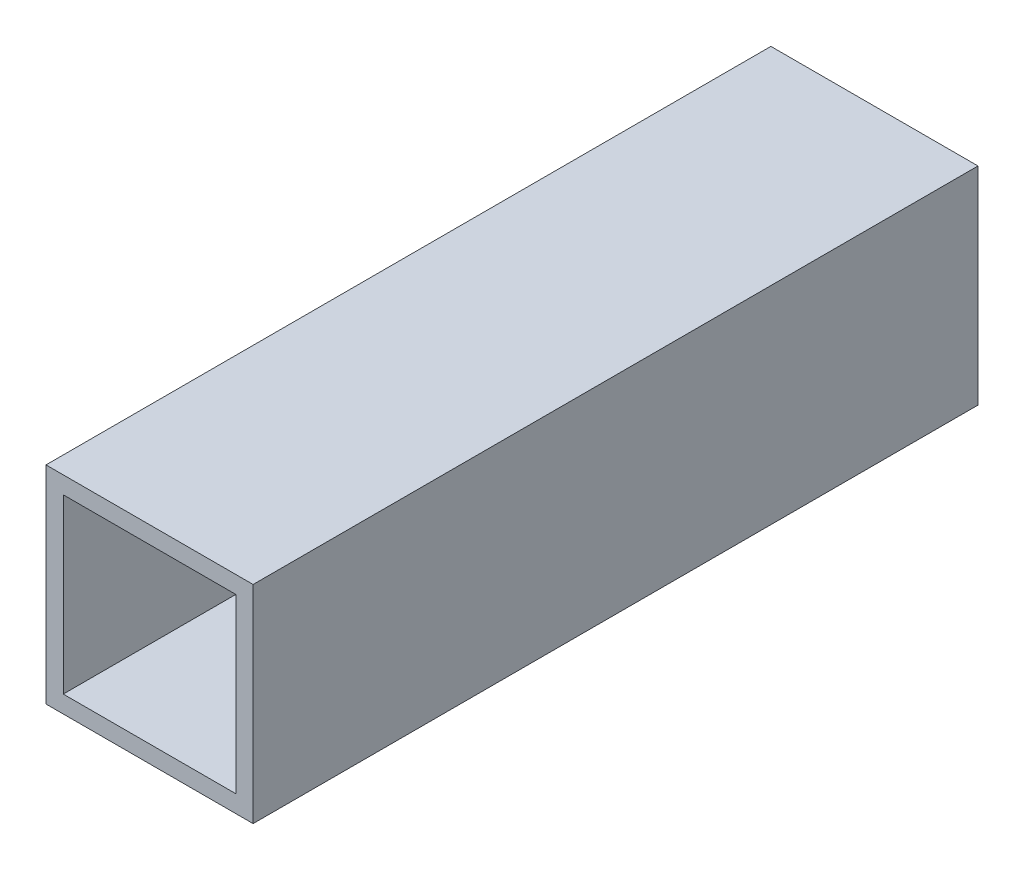
from build123d import *

# Parameters (mm, degrees)
SKETCH1_W           = 38.1
SKETCH1_H           = 133.35
BOSS_EXTRUDE1_DEPTH = 19.05
SKETCH2_W           = 31.75
SKETCH2_H           = 31.75
CUT_EXTRUDE1_DEPTH  = 134.35


with BuildPart() as part:
    # Sketch1 → Boss-Extrude1 (new body, symmetric)
    with BuildSketch(Plane(origin=(0, 0, 0), x_dir=(1, 0, 0), z_dir=(0, 1, 0))):
        Rectangle(SKETCH1_W, SKETCH1_H)
    extrude(amount=BOSS_EXTRUDE1_DEPTH, both=True)

    # Sketch2 → Cut-Extrude1 (cut, through all)
    with BuildSketch(Plane.XY.offset(66.675)):
        Rectangle(SKETCH2_W, SKETCH2_H)
    extrude(amount=-CUT_EXTRUDE1_DEPTH, mode=Mode.SUBTRACT)


solid = part.part
